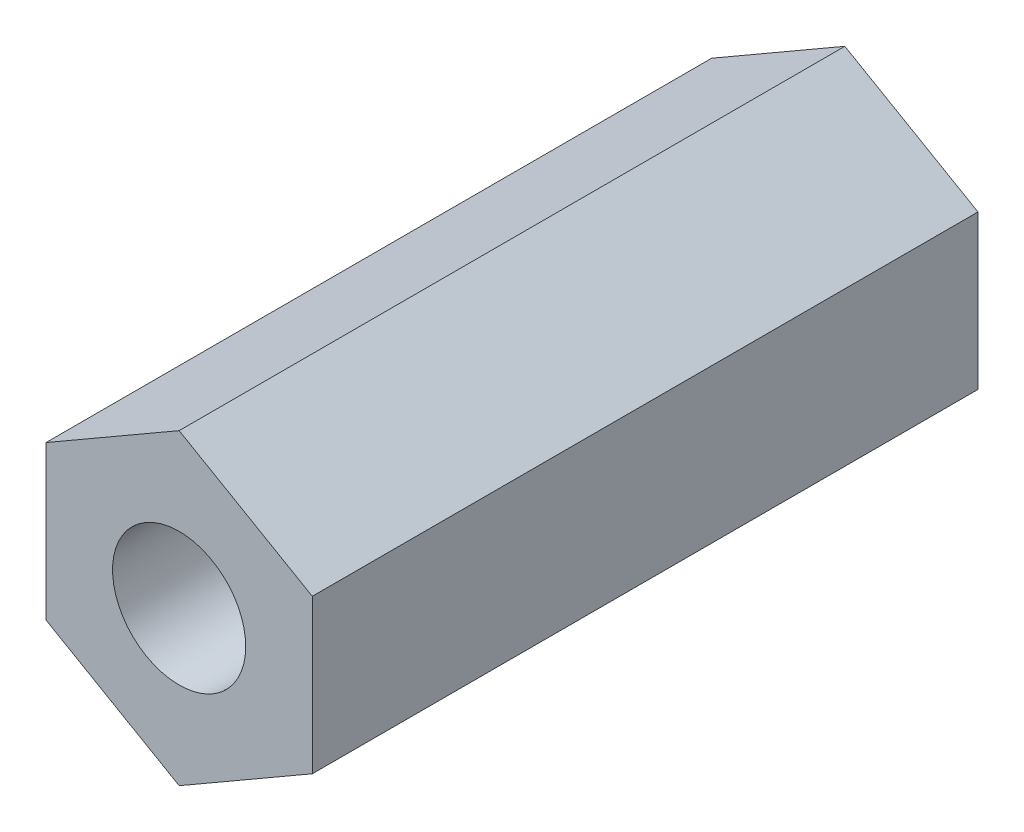
from build123d import *

# Parameters (mm, degrees)
BOSS_EXTRU_1_DEPTH      = 15
ESQUISSE2_R             = 1.5
ENL_V_MAT_EXTRU_1_DEPTH = 5
ESQUISSE3_R             = 1.5
ENL_V_MAT_EXTRU_2_DEPTH = 5


with BuildPart() as part:
    # Esquisse1 → Boss.-Extru.1 (new body)
    with BuildSketch(Plane.XY):
        Polygon((0, -3.464101615), (3, -1.732050808), (3, 1.732050808), (0, 3.464101615), (-3, 1.732050808), (-3, -1.732050808), align=None)
    extrude(amount=BOSS_EXTRU_1_DEPTH)

    # Esquisse2 → Enlèv. mat.-Extru.1 (cut)
    with BuildSketch(Plane(origin=(0, 0, 0), x_dir=(-1, 0, 0), z_dir=(0, 0, -1))):
        Circle(ESQUISSE2_R)
    extrude(amount=-ENL_V_MAT_EXTRU_1_DEPTH, mode=Mode.SUBTRACT)

    # Esquisse3 → Enlèv. mat.-Extru.2 (cut)
    with BuildSketch(Plane.XY.offset(15)):
        Circle(ESQUISSE3_R)
    extrude(amount=-ENL_V_MAT_EXTRU_2_DEPTH, mode=Mode.SUBTRACT)


solid = part.part
